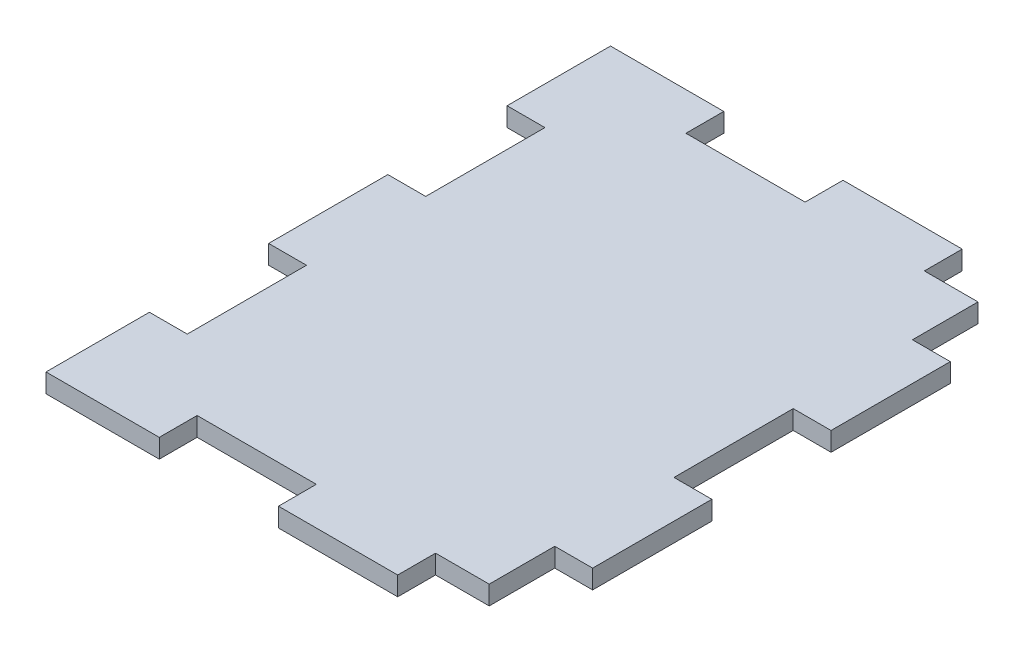
from build123d import *

# Parameters (mm, degrees)
SKETCH1_W           = 37.175
SKETCH1_H           = 47.35
BOSS_EXTRUDE1_DEPTH = 1.5875
SKETCH2_W           = 3.175
SKETCH2_H           = 10
SKETCH2_H_2         = 5.5
SKETCH2_W_2         = 10
SKETCH2_H_3         = 3.175
CUT_EXTRUDE1_DEPTH  = 2.5875


with BuildPart() as part:
    # Sketch1 → Boss-Extrude1 (new body)
    with BuildSketch(Plane(origin=(0, 0, 0), x_dir=(1, 0, 0), z_dir=(0, 1, 0))):
        with Locations((18.5875, 23.675)):
            Rectangle(SKETCH1_W, SKETCH1_H)
    extrude(amount=BOSS_EXTRUDE1_DEPTH)

    # Sketch2 → Cut-Extrude1 (cut, through all)
    with BuildSketch(Plane(origin=(0, 1.5875, 0), x_dir=(1, 0, 0), z_dir=(0, 1, 0))):
        Polygon((37.175, 47.35), (29.5, 47.35), (29.5, 44.175), (34, 44.175), (34, 38.675), (37.175, 38.675), align=None)
        with Locations((35.5875, 23.675)):
            Rectangle(SKETCH2_W, SKETCH2_H)
        Polygon((29.5, 3.175), (29.5, 0), (37.175, 0), (37.175, 3.175), (34, 3.175), align=None)
        with Locations((35.5875, 5.925)):
            Rectangle(SKETCH2_W, SKETCH2_H_2)
        with Locations((14.5, 1.5875)):
            Rectangle(SKETCH2_W_2, SKETCH2_H_3)
        with Locations((1.5875, 13.675)):
            Rectangle(SKETCH2_W, SKETCH2_H)
        with Locations((1.5875, 33.675)):
            Rectangle(SKETCH2_W, SKETCH2_H)
        with Locations((14.5, 45.7625)):
            Rectangle(SKETCH2_W_2, SKETCH2_H_3)
    extrude(amount=-CUT_EXTRUDE1_DEPTH, mode=Mode.SUBTRACT)


solid = part.part
